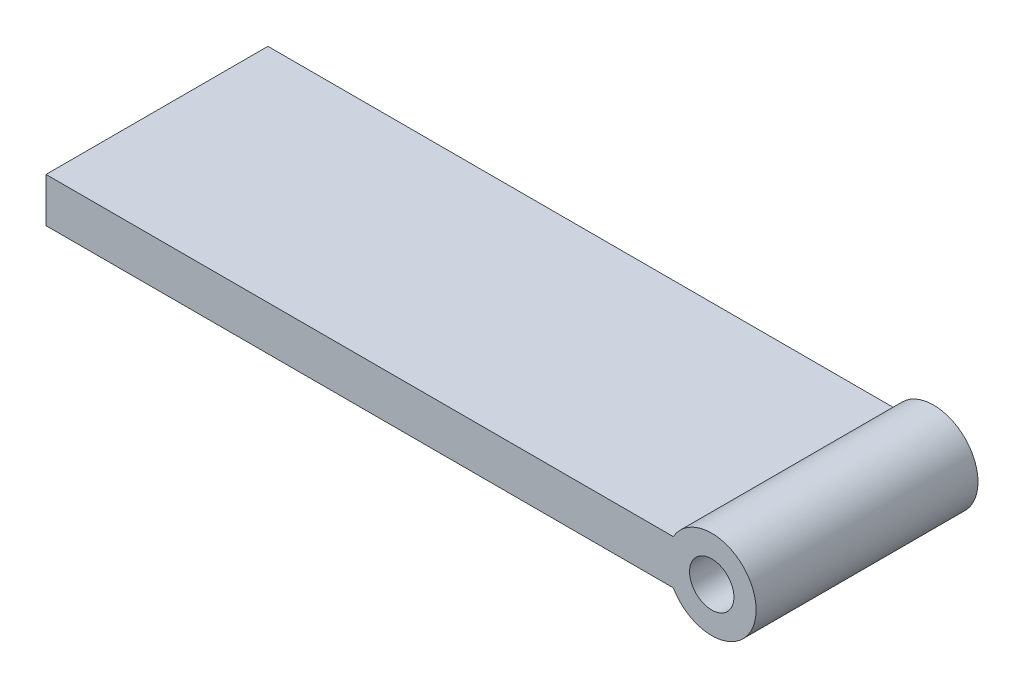
from build123d import *

# Parameters (mm, degrees)
SKETCH1_W           = 150
SKETCH1_H           = 50
BOSS_EXTRUDE1_DEPTH = 10
SKETCH2_R           = 10
BOSS_EXTRUDE2_DEPTH = 50
SKETCH3_R           = 5
CUT_EXTRUDE1_DEPTH  = 51


with BuildPart() as part:
    # Sketch1 → Boss-Extrude1 (new body)
    with BuildSketch(Plane(origin=(0, 0, 0), x_dir=(1, 0, 0), z_dir=(0, 1, 0))):
        with Locations((-75, 25)):
            Rectangle(SKETCH1_W, SKETCH1_H)
    extrude(amount=BOSS_EXTRUDE1_DEPTH)

    # Sketch2 → Boss-Extrude2 (add, through all)
    with BuildSketch(Plane.XY):
        with Locations((0, 5)):
            Circle(SKETCH2_R)
    extrude(amount=-BOSS_EXTRUDE2_DEPTH)

    # Sketch3 → Cut-Extrude1 (cut, through all)
    with BuildSketch(Plane.XY):
        with Locations((0, 5)):
            Circle(SKETCH3_R)
    extrude(amount=-CUT_EXTRUDE1_DEPTH, mode=Mode.SUBTRACT)


solid = part.part
